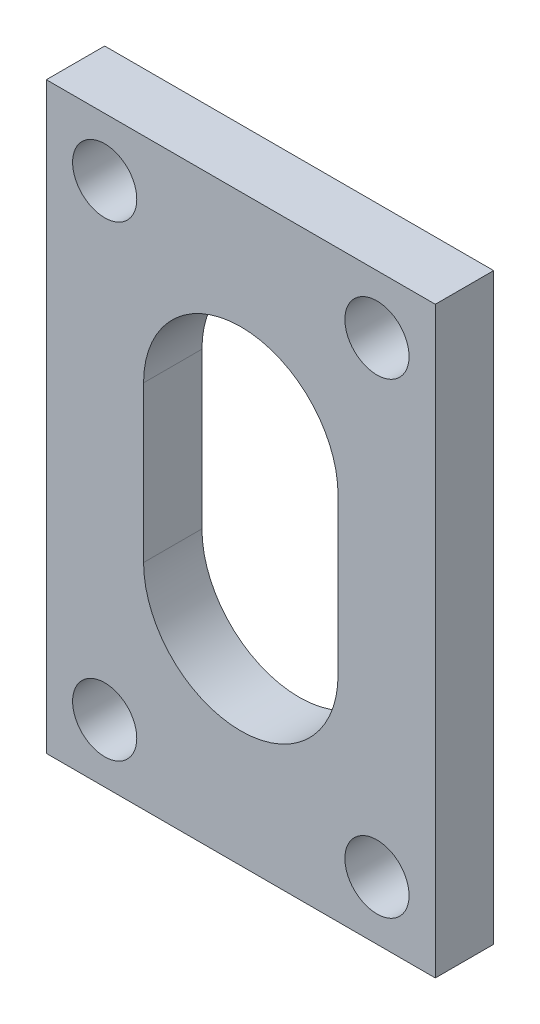
from build123d import *

# Parameters (mm, degrees)
CROQUIS1_W              = 20
CROQUIS1_H              = 30
CROQUIS1_R              = 1.65
SALIENTE_EXTRUIR1_DEPTH = 3
CORTAR_EXTRUIR1_REACH   = 5


with BuildPart() as part:
    # Croquis1 → Saliente-Extruir1 (new body)
    with BuildSketch(Plane.XY):
        Rectangle(CROQUIS1_W, CROQUIS1_H)
        with Locations((-7, 12)):
            Circle(CROQUIS1_R, mode=Mode.SUBTRACT)
        with Locations((7, 12)):
            Circle(CROQUIS1_R, mode=Mode.SUBTRACT)
        with Locations((7, -12)):
            Circle(CROQUIS1_R, mode=Mode.SUBTRACT)
        with Locations((-7, -12)):
            Circle(CROQUIS1_R, mode=Mode.SUBTRACT)
    extrude(amount=SALIENTE_EXTRUIR1_DEPTH)

    # Croquis2 → Cortar-Extruir1 (cut, up to next)
    with BuildSketch(Plane.XY.offset(3), mode=Mode.PRIVATE) as cortar_extruir1_sk1:
        with BuildLine():
            Line((-5, -4), (-5, 4))
            ThreePointArc((-5, 4), (0, 9), (5, 4))
            Line((5, 4), (5, -4))
            ThreePointArc((5, -4), (0, -9), (-5, -4))
        make_face()
    cortar_extruir1_tool1 = extrude(cortar_extruir1_sk1.sketch, amount=-CORTAR_EXTRUIR1_REACH, mode=Mode.PRIVATE) & part.part
    add(cortar_extruir1_tool1.solids().sort_by_distance((0, 0, 3))[0], mode=Mode.SUBTRACT)


solid = part.part
